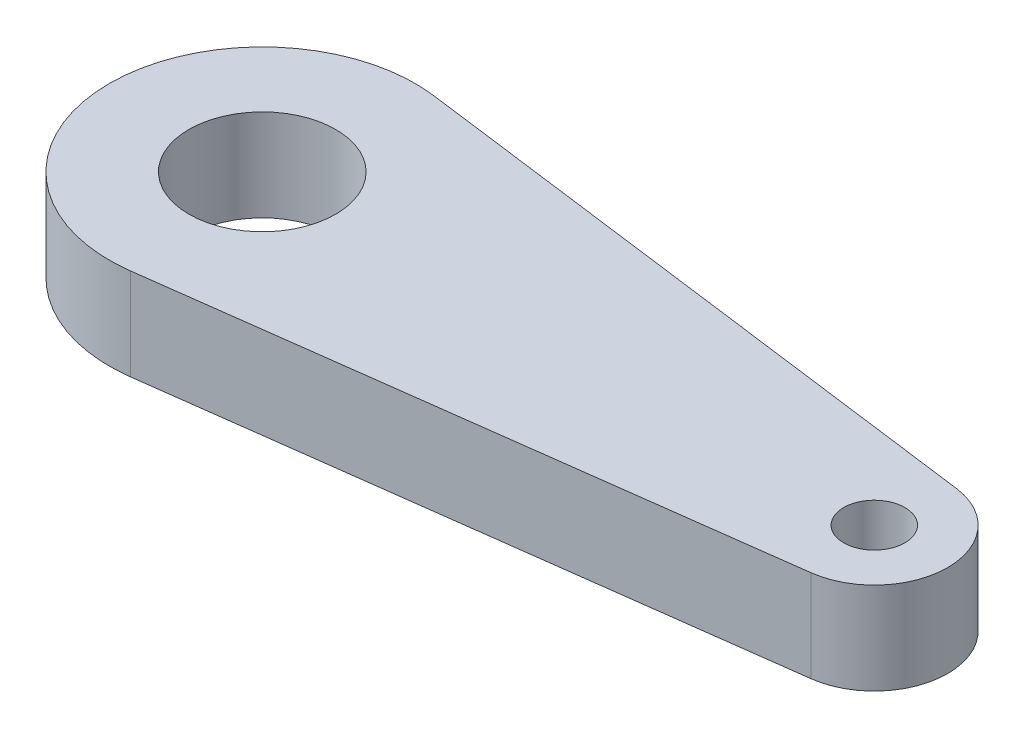
from build123d import *

# Parameters (mm, degrees)
SKETCH2_R           = 2.5
SKETCH2_R_2         = 6
BOSS_EXTRUDE1_DEPTH = 7.5


with BuildPart() as part:
    # Sketch2 → Boss-Extrude1 (new body)
    with BuildSketch(Plane(origin=(0, 0, 0), x_dir=(1, 0, 0), z_dir=(0, 1, 0))):
        with BuildLine():
            Line((-22.285577553, 12.393924923), (26.869422447, 5.949083963))
            ThreePointArc((26.869422447, 5.949083963), (32.089422447, 0), (26.869422447, -5.949083963))
            Line((26.869422447, -5.949083963), (-22.285577553, -12.393924923))
            ThreePointArc((-22.285577553, -12.393924923), (-36.410577553, 0), (-22.285577553, 12.393924923))
        make_face()
        with Locations((26.089422447, 0)):
            Circle(SKETCH2_R, mode=Mode.SUBTRACT)
        with Locations((-23.910577553, 0)):
            Circle(SKETCH2_R_2, mode=Mode.SUBTRACT)
    extrude(amount=BOSS_EXTRUDE1_DEPTH)


solid = part.part
